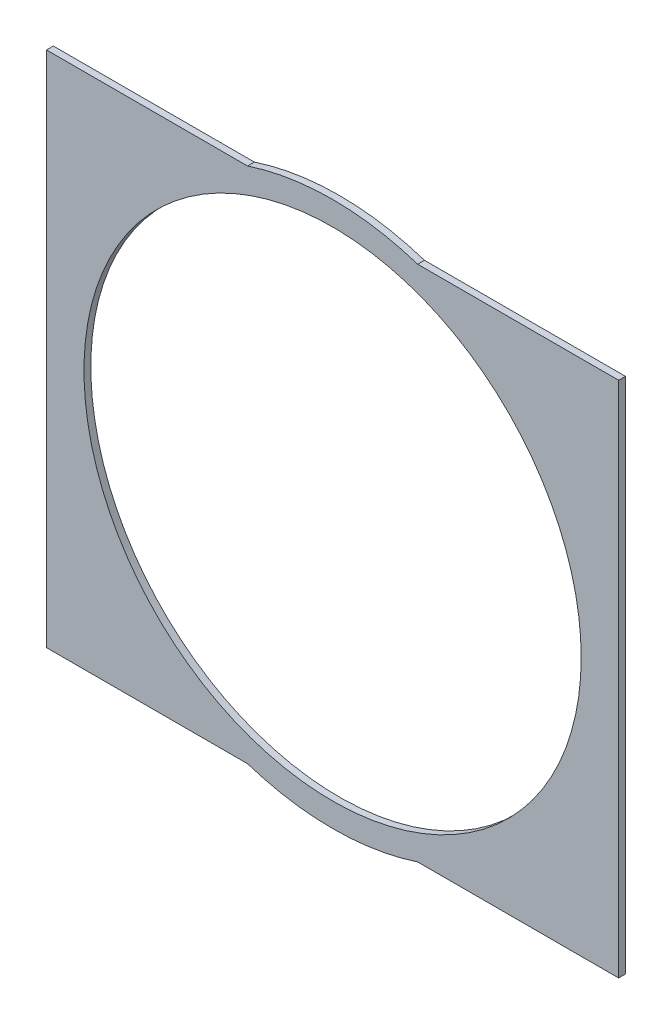
from build123d import *

# Parameters (mm, degrees)
SKETCH1_R           = 36.5
BOSS_EXTRUDE1_DEPTH = 1


with BuildPart() as part:
    # Sketch1 → Boss-Extrude1 (new body)
    with BuildSketch(Plane.XY):
        with BuildLine():
            Line((-29.510004003, 0), (0, 0))
            Line((0, 0), (0, 76))
            Line((0, 76), (-29.510004003, 76))
            ThreePointArc((-29.510004003, 76), (-42, 78), (-54.489995997, 76))
            Line((-54.489995997, 76), (-84, 76))
            Line((-84, 76), (-84, 0))
            Line((-84, 0), (-54.489995997, 0))
            ThreePointArc((-54.489995997, 0), (-42, -2), (-29.510004003, 0))
        make_face()
        with Locations((-42, 38)):
            Circle(SKETCH1_R, mode=Mode.SUBTRACT)
    extrude(amount=BOSS_EXTRUDE1_DEPTH)


solid = part.part
